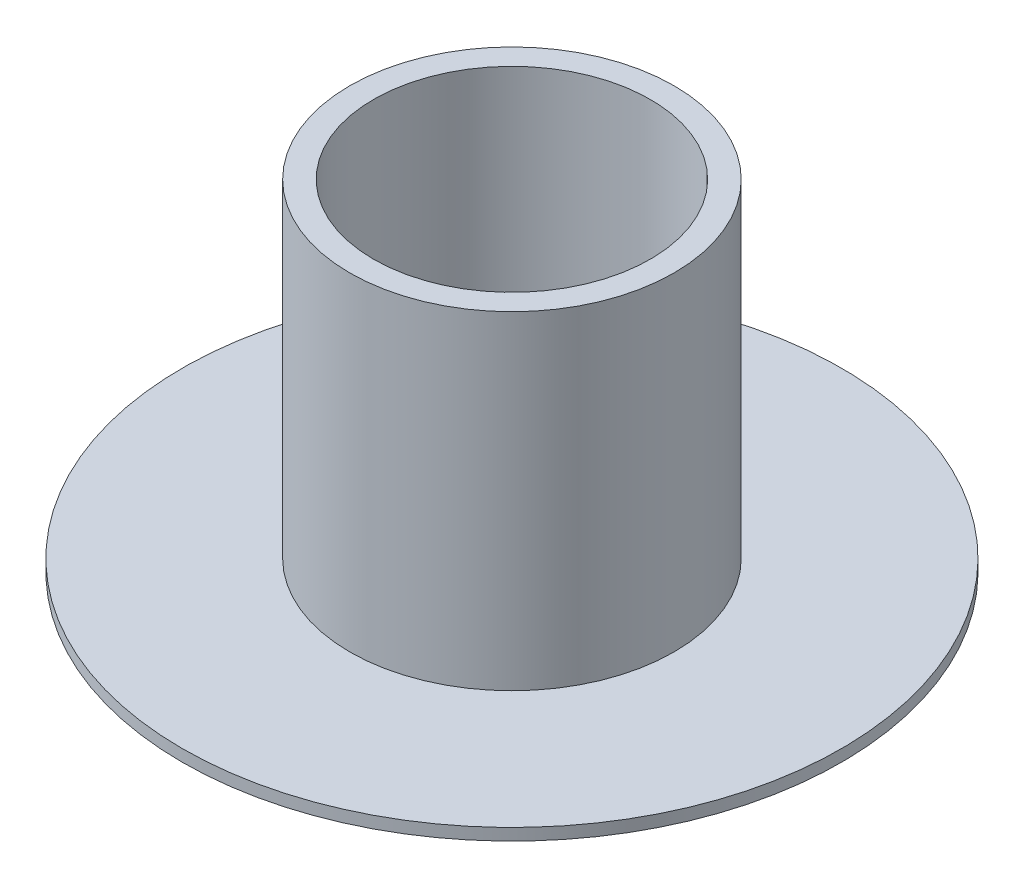
from build123d import *


with BuildPart() as part:
    # Croquis1 → Revolución1 (revolve)
    with BuildSketch(Plane.XY):
        Polygon((-50.051003135, 1.720724123), (-64.551003135, 1.720724123), (-64.551003135, 2.620724123), (-51.851003135, 2.620724123), (-51.851003135, 27.520724123), (-50.051003135, 27.520724123), align=None)
    revolve(axis=Axis((-39.551003135, 23.65836726, 0), (0, -1, 0)))


solid = part.part
